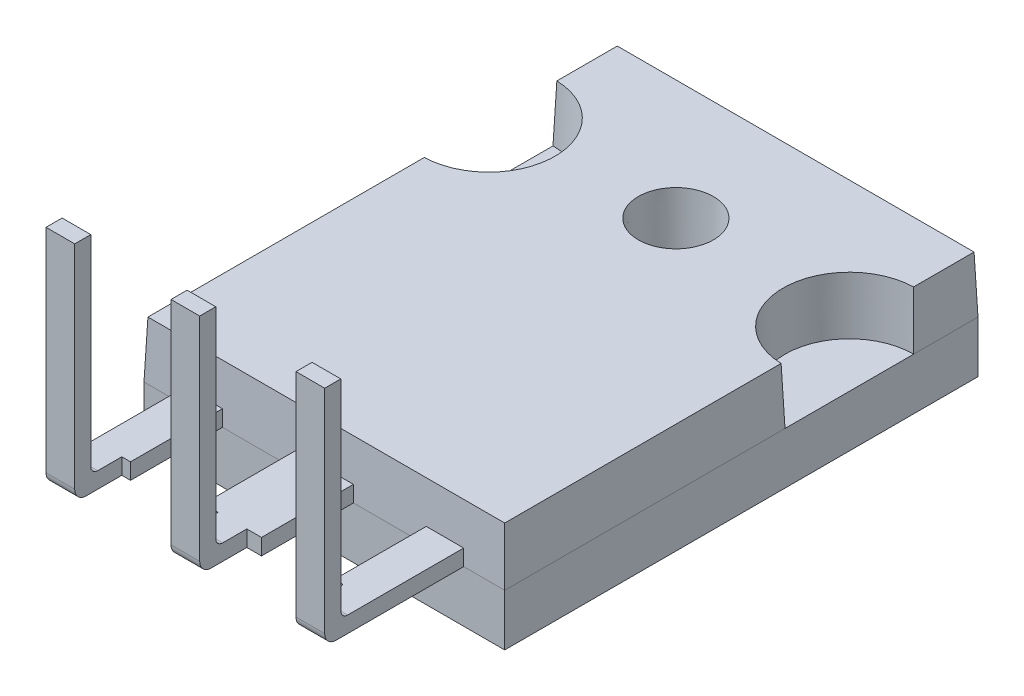
from build123d import *

# Parameters (mm, degrees)
SKETCH_1_W        = 15.7
SKETCH_1_H        = 20.6
SKETCH_1_R        = 1.55
EXTRUDE_1_DEPTH   = 2.25
SKETCH_2_R        = 1.55
EXTRUDE_2_DEPTH   = 2.45
EXTRUDE_2_DRAFT   = 2
EXTRUDE_3_DEPTH   = 0.7
EXTRUDE_3_2_DEPTH = 0.7
EXTRUDE_3_3_DEPTH = 0.7
SKETCH_3_W        = 1.25
SKETCH_3_H        = 0.7
EXTRUDE_4_DEPTH   = 9.05
FILLET_1_R        = 0.3
FILLET_2_R        = 0.3
FILLET_3_R        = 0.3
FILLET_4_R        = 0.5
FILLET_5_R        = 0.5
FILLET_6_R        = 0.5


with BuildPart() as part:
    # Эскиз1 → Бобышка-Вытянуть1 (new body)
    with BuildSketch(Plane(origin=(0, 0, 0), x_dir=(1, 0, 0), z_dir=(0, 1, 0))):
        Rectangle(SKETCH_1_W, SKETCH_1_H)
        with Locations((0, 5)):
            Circle(SKETCH_1_R, mode=Mode.SUBTRACT)
    extrude(amount=EXTRUDE_1_DEPTH)


with BuildPart() as extrude_2_tool:
    # Эскиз2 → Бобышка-Вытянуть2 (with draft: the straight prism first)
    with BuildSketch(Plane(origin=(0, 2.25, 0), x_dir=(1, 0, 0), z_dir=(0, 1, 0))):
        with BuildLine():
            ThreePointArc((-7.85, 7.5), (-5.05, 4.7), (-7.85, 1.9))
            Line((-7.85, 1.9), (-7.85, -10.3))
            Line((-7.85, -10.3), (-6.065, -10.3))
            Line((-6.065, -10.3), (-4.435, -10.3))
            Line((-4.435, -10.3), (-1.265, -10.3))
            Line((-1.265, -10.3), (1.265, -10.3))
            Line((1.265, -10.3), (4.435, -10.3))
            Line((4.435, -10.3), (6.065, -10.3))
            Line((6.065, -10.3), (7.85, -10.3))
            Line((7.85, -10.3), (7.85, 1.9))
            ThreePointArc((7.85, 1.9), (5.05, 4.7), (7.85, 7.5))
            Line((7.85, 7.5), (7.85, 10.3))
            Line((7.85, 10.3), (-7.85, 10.3))
            Line((-7.85, 10.3), (-7.85, 7.5))
        make_face()
        with Locations((0, 5)):
            Circle(SKETCH_2_R, mode=Mode.SUBTRACT)
    extrude(amount=EXTRUDE_2_DEPTH)
    # Бобышка-Вытянуть2: the draft: its side faces are tilted about the plane it starts from
    extrude_2_sides = [extrude_2_tool.faces().sort_by_distance(p)[0] for p in [
        (-5.05, 3.475, -4.7),
        (-1.55, 3.475, -5),
        (0, 3.475, -10.3),
        (7.85, 3.475, -8.9),
        (5.05, 3.475, -4.7),
        (7.85, 3.475, 4.2),
        (0, 3.475, 10.3),
        (-7.85, 3.475, 4.2),
        (-7.85, 3.475, -8.9),
    ]]
    draft(extrude_2_sides, Plane(origin=(0, 2.25, 0), x_dir=(1, 0, 0), z_dir=(0, 1, 0)), EXTRUDE_2_DRAFT)


with BuildPart() as part_1:
    add(part.part)

    # Бобышка-Вытянуть2: add extrude_2_tool
    add(extrude_2_tool.part)


with BuildPart() as body_2:
    # Эскиз2<4> → Бобышка-Вытянуть3 (new body)
    with BuildSketch(Plane(origin=(0, 2.25, 0), x_dir=(1, 0, 0), z_dir=(0, 1, 0))):
        Polygon((-4.435, -10.3), (-6.065, -10.3), (-6.065, -16.35), (-4.815, -16.35), (-4.815, -14.3), (-4.435, -14.3), align=None)
    extrude(amount=EXTRUDE_3_DEPTH)



with BuildPart() as body_3:
    # Эскиз2<4> → Extrude 3 2 (new body)
    with BuildSketch(Plane(origin=(0, 2.25, 0), x_dir=(1, 0, 0), z_dir=(0, 1, 0))):
        Polygon((1.265, -10.3), (-1.265, -10.3), (-1.265, -14.3), (-0.625, -14.3), (-0.625, -16.35), (0.625, -16.35), (0.625, -14.3), (1.265, -14.3), align=None)
    extrude(amount=EXTRUDE_3_2_DEPTH)


with BuildPart() as body_4:
    # Эскиз2<4> → Extrude 3 3 (new body)
    with BuildSketch(Plane(origin=(0, 2.25, 0), x_dir=(1, 0, 0), z_dir=(0, 1, 0))):
        Polygon((6.065, -10.3), (4.435, -10.3), (4.435, -14.3), (4.815, -14.3), (4.815, -16.35), (6.065, -16.35), align=None)
    extrude(amount=EXTRUDE_3_3_DEPTH)


with BuildPart() as body_2_1:
    add(body_2.part)

    add(body_3.part)  # Бобышка-Вытянуть4 merges body 3

    add(body_4.part)  # Бобышка-Вытянуть4 merges body 4
    # Эскиз3 → Бобышка-Вытянуть4 (add)
    with BuildSketch(Plane(origin=(0, 2.95, 0), x_dir=(1, 0, 0), z_dir=(0, 1, 0))):
        with Locations((-5.44, -16)):
            Rectangle(SKETCH_3_W, SKETCH_3_H)
        with Locations((0, -16)):
            Rectangle(SKETCH_3_W, SKETCH_3_H)
        with Locations((5.44, -16)):
            Rectangle(SKETCH_3_W, SKETCH_3_H)
    extrude(amount=EXTRUDE_4_DEPTH)

    # Скругление1
    fillet_1_edges = [body_2_1.edges().sort_by_distance(p)[0] for p in [
        (5.44, 2.95, 15.65),
    ]]
    fillet(fillet_1_edges, radius=FILLET_1_R)

    # Скругление2
    fillet_2_edges = [body_2_1.edges().sort_by_distance(p)[0] for p in [
        (0, 2.95, 15.65),
    ]]
    fillet(fillet_2_edges, radius=FILLET_2_R)

    # Скругление3
    fillet_3_edges = [body_2_1.edges().sort_by_distance(p)[0] for p in [
        (-5.44, 2.95, 15.65),
    ]]
    fillet(fillet_3_edges, radius=FILLET_3_R)

    # Скругление4
    fillet_4_edges = [body_2_1.edges().sort_by_distance(p)[0] for p in [
        (5.44, 2.25, 16.35),
    ]]
    fillet(fillet_4_edges, radius=FILLET_4_R)

    # Скругление5
    fillet_5_edges = [body_2_1.edges().sort_by_distance(p)[0] for p in [
        (0, 2.25, 16.35),
    ]]
    fillet(fillet_5_edges, radius=FILLET_5_R)

    # Скругление6
    fillet_6_edges = [body_2_1.edges().sort_by_distance(p)[0] for p in [
        (-5.44, 2.25, 16.35),
    ]]
    fillet(fillet_6_edges, radius=FILLET_6_R)


solid = Compound([part_1.part, body_2_1.part])
